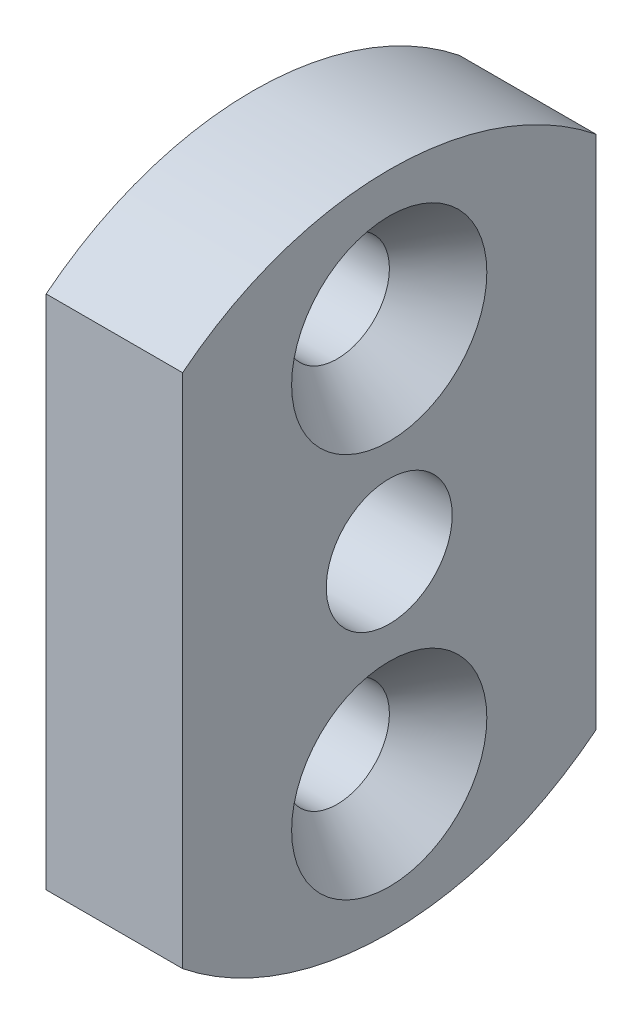
from build123d import *

# Parameters (mm, degrees)
SKETCH1_R                                      = 1.7272
SKETCH1_R_2                                    = 2.286
BOSS_EXTRUDE1_DEPTH                            = 4.953
CSK_FOR_6_FLAT_HEAD_MACHINE_SCREW1_D           = 3.7973
CSK_FOR_6_FLAT_HEAD_MACHINE_SCREW1_DEPTH       = 10.973
CSK_FOR_6_FLAT_HEAD_MACHINE_SCREW1_CSINK_D     = 7.0866
CSK_FOR_6_FLAT_HEAD_MACHINE_SCREW1_CSINK_ANGLE = 82
CSK_FOR_6_FLAT_HEAD_MACHINE_SCREW1_TIP         = 1.140824014


with BuildPart() as part:
    # Sketch1 → Boss-Extrude1 (new body)
    with BuildSketch(Plane(origin=(0, 0, 0), x_dir=(0, 0, -1), z_dir=(1, 0, 0))):
        with BuildLine():
            Line((-7.5, 9.367496998), (-7.5, -9.367496998))
            ThreePointArc((-7.5, -9.367496998), (0, -12), (7.5, -9.367496998))
            Line((7.5, -9.367496998), (7.5, 9.367496998))
            ThreePointArc((7.5, 9.367496998), (0, 12), (-7.5, 9.367496998))
        make_face()
        with Locations((0, 7)):
            Circle(SKETCH1_R, mode=Mode.SUBTRACT)
        with Locations((0, -7)):
            Circle(SKETCH1_R, mode=Mode.SUBTRACT)
        Circle(SKETCH1_R_2, mode=Mode.SUBTRACT)
    extrude(amount=BOSS_EXTRUDE1_DEPTH)

    # CSK for _6 Flat Head Machine Screw1
    with Locations(Plane(origin=(4.953, 0, 0), x_dir=(0, 0, -1), z_dir=(1, 0, 0))):
        with Locations((0, -7), (0, 7)):
            CounterSinkHole(CSK_FOR_6_FLAT_HEAD_MACHINE_SCREW1_D / 2, CSK_FOR_6_FLAT_HEAD_MACHINE_SCREW1_CSINK_D / 2, depth=CSK_FOR_6_FLAT_HEAD_MACHINE_SCREW1_DEPTH, counter_sink_angle=CSK_FOR_6_FLAT_HEAD_MACHINE_SCREW1_CSINK_ANGLE)
            with Locations((0, 0, -(CSK_FOR_6_FLAT_HEAD_MACHINE_SCREW1_DEPTH + CSK_FOR_6_FLAT_HEAD_MACHINE_SCREW1_TIP / 2))):  # 118° drill point
                Cone(0, CSK_FOR_6_FLAT_HEAD_MACHINE_SCREW1_D / 2, CSK_FOR_6_FLAT_HEAD_MACHINE_SCREW1_TIP, mode=Mode.SUBTRACT)


solid = part.part
